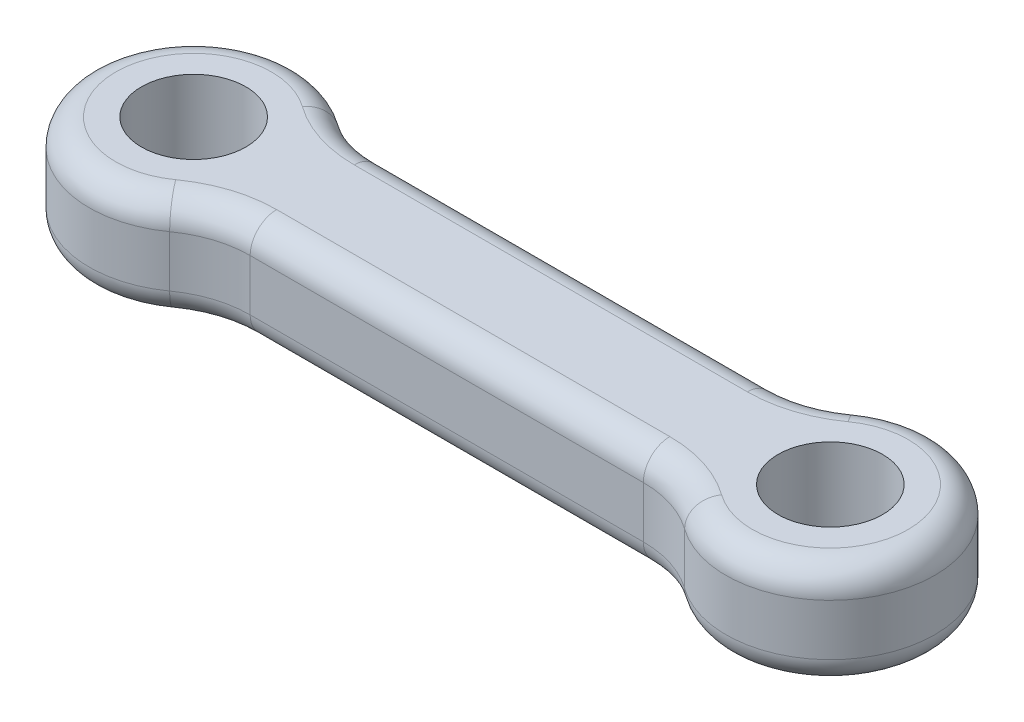
from build123d import *

# Parameters (mm, degrees)
SKETCH1_R           = 5
BOSS_EXTRUDE1_DEPTH = 10
FILLET1_R           = 2.54
SCALE1_SCALE        = 0.66


with BuildPart() as part:
    # Sketch1 → Boss-Extrude1 (new body)
    with BuildSketch(Plane(origin=(0, 0, 0), x_dir=(1, 0, 0), z_dir=(0, 1, 0))):
        with BuildLine():
            Line((-3.580776184, -6.25), (34.060776184, -6.25))
            ThreePointArc((34.060776184, -6.25), (37.122638362, -6.730283618), (39.890388092, -8.125))
            ThreePointArc((39.890388092, -8.125), (55.72, 0), (39.890388092, 8.125))
            ThreePointArc((39.890388092, 8.125), (37.122638362, 6.730283618), (34.060776184, 6.25))
            Line((34.060776184, 6.25), (-3.580776184, 6.25))
            ThreePointArc((-3.580776184, 6.25), (-6.642638362, 6.730283618), (-9.410388092, 8.125))
            ThreePointArc((-9.410388092, 8.125), (-25.24, 0), (-9.410388092, -8.125))
            ThreePointArc((-9.410388092, -8.125), (-6.642638362, -6.730283618), (-3.580776184, -6.25))
        make_face()
        with Locations((-15.24, 0)):
            Circle(SKETCH1_R, mode=Mode.SUBTRACT)
        with Locations((45.72, 0)):
            Circle(SKETCH1_R, mode=Mode.SUBTRACT)
    extrude(amount=BOSS_EXTRUDE1_DEPTH)

    # Fillet1
    fillet1_edges = [part.edges().sort_by_distance(p)[0] for p in [
        (-6.642638362, 10, 6.730283618),
        (-25.24, 0, 0),
        (-6.642638362, 0, -6.730283618),
        (15.24, 10, 6.25),
        (37.122638362, 10, 6.730283618),
        (55.72, 10, 0),
        (37.122638362, 10, -6.730283618),
        (15.24, 10, -6.25),
        (-6.642638362, 10, -6.730283618),
        (-25.24, 10, 0),
        (15.24, 0, -6.25),
        (37.122638362, 0, -6.730283618),
        (55.72, 0, 0),
        (37.122638362, 0, 6.730283618),
        (15.24, 0, 6.25),
        (-6.642638362, 0, 6.730283618),
    ]]
    fillet(fillet1_edges, radius=FILLET1_R)


with BuildPart() as part_1:
    # Scale1: scaled about (15.24, 5, 0)
    add(part.part.scale(SCALE1_SCALE).moved(Location((5.1816, 1.7, 0))))


solid = part_1.part
